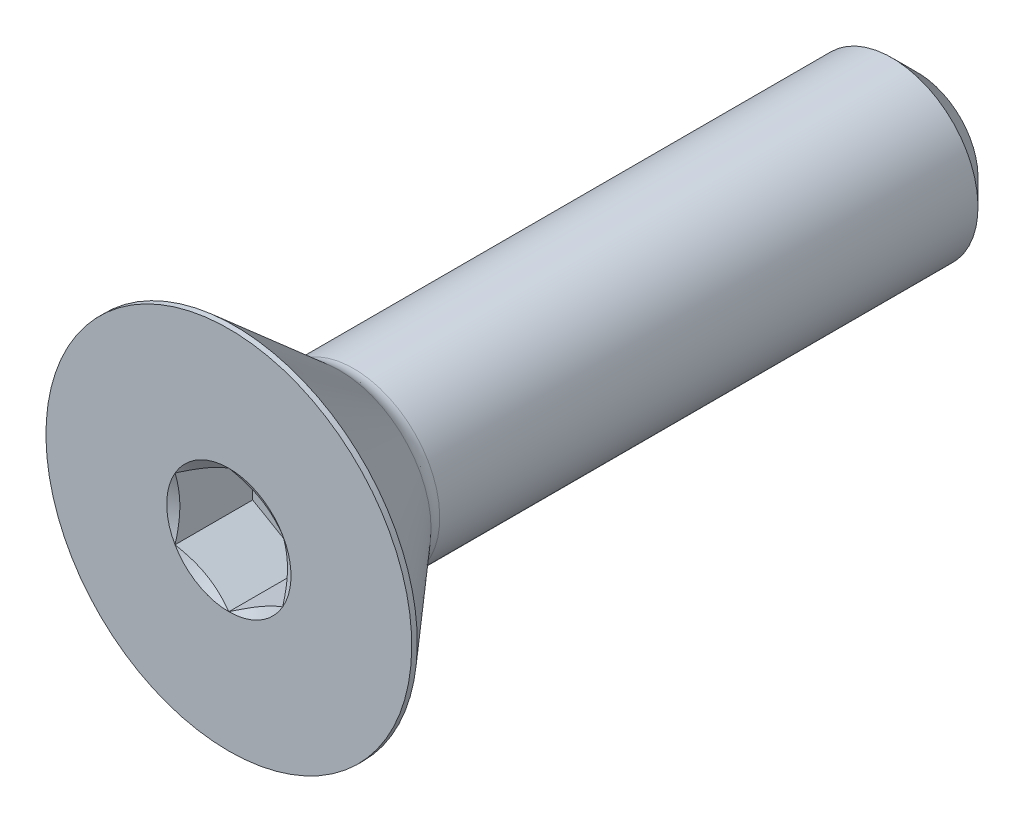
from build123d import *

# Parameters (mm, degrees)
SKETCH1_W          = 25.4
SKETCH1_H          = 3.175
CHAMFER1_SIZE      = 0.9525
CUT_EXTRUDE2_DEPTH = 2.86258


with BuildPart() as part:
    # Sketch1 → Revolve1 (revolve)
    with BuildSketch(Plane(origin=(0, 0, 0), x_dir=(0, 0, -1), z_dir=(1, 0, 0))):
        with Locations((12.7, 1.5875)):
            Rectangle(SKETCH1_W, SKETCH1_H)
    revolve(axis=Axis((0, 0, -25.4), (0, 0, 1)))

    # Chamfer1
    chamfer1_edges = [part.edges().sort_by_distance(p)[0] for p in [
        (0, -3.175, -25.4),
    ]]
    chamfer(chamfer1_edges, length=CHAMFER1_SIZE)

    # Sketch7 → Revolve2 (revolve)
    with BuildSketch(Plane(origin=(0, 0, 0), x_dir=(0, 0, -1), z_dir=(1, 0, 0)), mode=Mode.PRIVATE) as revolve2_sk:
        with BuildLine():
            Line((0, 6.7437), (0.20447, 6.7437))
            Line((0.20447, 6.7437), (4.0894, 3.366581874))
            ThreePointArc((4.0894, 3.366581874), (4.328282675, 3.224461616), (4.601808997, 3.175))
            Line((4.601808997, 3.175), (4.601808997, 0))
            Line((4.601808997, 0), (0, 0))
            Line((0, 0), (0, 6.7437))
        make_face()
    revolve(revolve2_sk.sketch.rotate(Axis((0, 0, 0), (0, 0, -1)), 180), axis=Axis((0, 0, 0), (0, 0, -1)))

    # Boss-Extrude1 cone 1 section (through the dimple's axis) → Boss-Extrude1 (revolve)
    with BuildSketch(Plane(origin=(0, 0, -4.601808997), x_dir=(0, -1, 0), z_dir=(1, 0, 0))):
        Polygon((0, 0), (3.175, 0), (0, 3.06606186), align=None)
    revolve(axis=Axis((0, 0, -4.601808997), (0, 0, -1)))

    # Sketch5 → Cut-Extrude2 (cut)
    with BuildSketch(Plane.XY):
        Polygon((0, 2.291358881), (-1.984375, 1.14567944), (-1.984375, -1.14567944), (0, -2.291358881), (1.984375, -1.14567944), (1.984375, 1.14567944), align=None)
    extrude(amount=-CUT_EXTRUDE2_DEPTH, mode=Mode.SUBTRACT)

    # Cut-Extrude3 cone 1 section (through the dimple's axis) → Cut-Extrude3 (revolve, cut)
    with BuildSketch(Plane(origin=(0, 0, 0), x_dir=(0, -1, 0), z_dir=(1, 0, 0))):
        Polygon((0, 0), (2.291358881, 0), (0, 1.322916667), align=None)
    revolve(axis=Axis((0, 0, 0), (0, 0, -1)), mode=Mode.SUBTRACT)


solid = part.part
